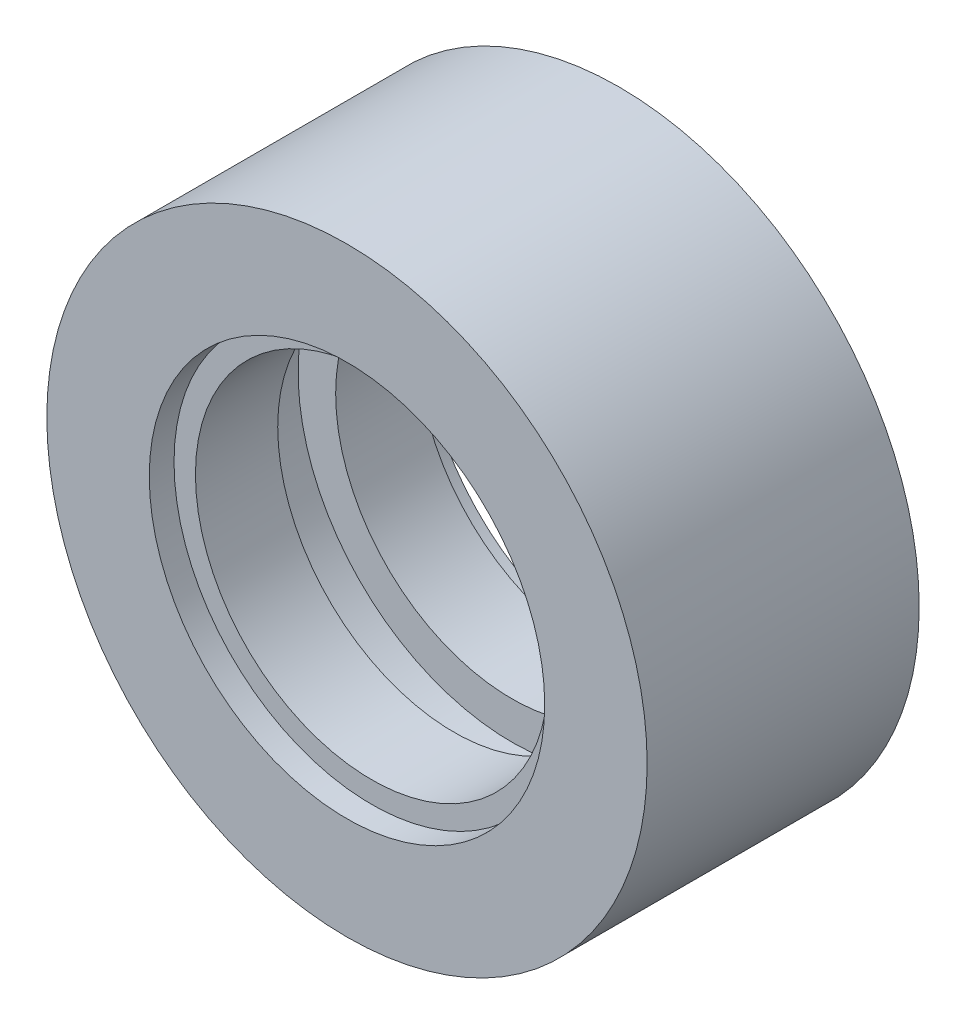
from build123d import *

# Parameters (mm, degrees)
SZKIC1_R                    = 14.3
DODANIE_WYCI_GNI_CIE1_DEPTH = 12.96
WYTNIJ_WYCI_GNI_CIE1_REACH  = 14.96
SZKIC2_R                    = 8.4
SZKIC3_R                    = 9.42
WYTNIJ_WYCI_GNI_CIE2_DEPTH  = 1.18
SZKIC5_R                    = 10.19
WYTNIJ_WYCI_GNI_CIE3_DEPTH  = 1.38


with BuildPart() as part:
    # Szkic1 → Dodanie-wyciągnięcie1 (new body)
    with BuildSketch(Plane.XY):
        Circle(SZKIC1_R)
    extrude(amount=DODANIE_WYCI_GNI_CIE1_DEPTH)

    # Szkic2 → Wytnij-wyciągnięcie1 (cut, up to next)
    with BuildSketch(Plane.XY.offset(12.96), mode=Mode.PRIVATE) as wytnij_wyci_gni_cie1_sk1:
        Circle(SZKIC2_R)
    wytnij_wyci_gni_cie1_tool1 = extrude(wytnij_wyci_gni_cie1_sk1.sketch, amount=-WYTNIJ_WYCI_GNI_CIE1_REACH, mode=Mode.PRIVATE) & part.part
    add(wytnij_wyci_gni_cie1_tool1.solids().sort_by_distance((0, 0, 12.96))[0], mode=Mode.SUBTRACT)

    # Szkic3 → Wytnij-wyciągnięcie2 (cut)
    with BuildSketch(Plane.XY.offset(12.96)):
        Circle(SZKIC3_R)
    wytnij_wyci_gni_cie2 = extrude(amount=-WYTNIJ_WYCI_GNI_CIE2_DEPTH, mode=Mode.SUBTRACT)

    # Lustro1: Wytnij-wyciągnięcie2 across plane
    add(wytnij_wyci_gni_cie2.mirror(Plane.XY.offset(6.48)), mode=Mode.SUBTRACT)

    # Szkic5 → Wytnij-wyciągnięcie3 (cut, symmetric)
    with BuildSketch(Plane.XY.offset(6.48)):
        Circle(SZKIC5_R)
    extrude(amount=WYTNIJ_WYCI_GNI_CIE3_DEPTH, both=True, mode=Mode.SUBTRACT)


solid = part.part
